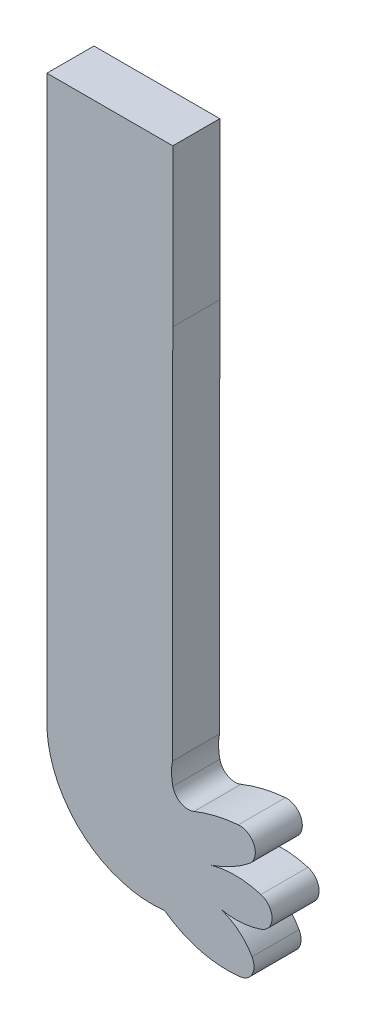
from build123d import *

# Parameters (mm, degrees)
SALIENTE_EXTRUIR1_DEPTH = 3


with BuildPart() as part:
    # Model → Saliente-Extruir1 (new body)
    with BuildSketch(Plane.XY):
        with BuildLine():
            Line((57.876051331, 16.193461244), (57.893981077, 40.180349578))
            Line((57.893981077, 40.180349578), (57.893981077, 50.180349578))
            Line((57.893981077, 50.180349578), (49.867941077, 50.180349578))
            Line((49.867941077, 50.180349578), (49.867941077, 31.597099578))
            Line((49.867941077, 31.597099578), (49.867941077, 14.013849578))
            ThreePointArc((49.867941077, 14.013849578), (52.233805345, 9.208034607), (57.367941077, 7.680349578))
            ThreePointArc((57.367941077, 7.680349578), (59.6653644, 6.596184281), (62.200359504, 6.430751104))
            ThreePointArc((62.200359504, 6.430751104), (62.9704791, 6.972225641), (62.949576341, 7.913417408))
            ThreePointArc((62.949576341, 7.913417408), (62.082712456, 8.936213823), (60.897352842, 9.562702519))
            ThreePointArc((60.897352842, 9.562702519), (62.218292049, 9.458452731), (63.516644878, 9.723081417))
            ThreePointArc((63.516644878, 9.723081417), (64.2274431, 10.680349578), (63.516644878, 11.637617739))
            ThreePointArc((63.516644878, 11.637617739), (61.945301969, 11.880701786), (60.367941077, 11.680349578))
            ThreePointArc((60.367941077, 11.680349578), (61.630469791, 12.22740936), (62.779023795, 12.985087958))
            ThreePointArc((62.779023795, 12.985087958), (63.087813038, 14.136299223), (62.075412289, 14.765332526))
            ThreePointArc((62.075412289, 14.765332526), (60.636782457, 14.535665244), (59.249346326, 14.091341219))
            ThreePointArc((59.249346326, 14.091341219), (58.409082944, 14.132037192), (57.897205789, 14.799630249))
            ThreePointArc((57.897205789, 14.799630249), (57.815004717, 15.495458697), (57.876051331, 16.193461244))
        make_face()
    extrude(amount=SALIENTE_EXTRUIR1_DEPTH)


solid = part.part
